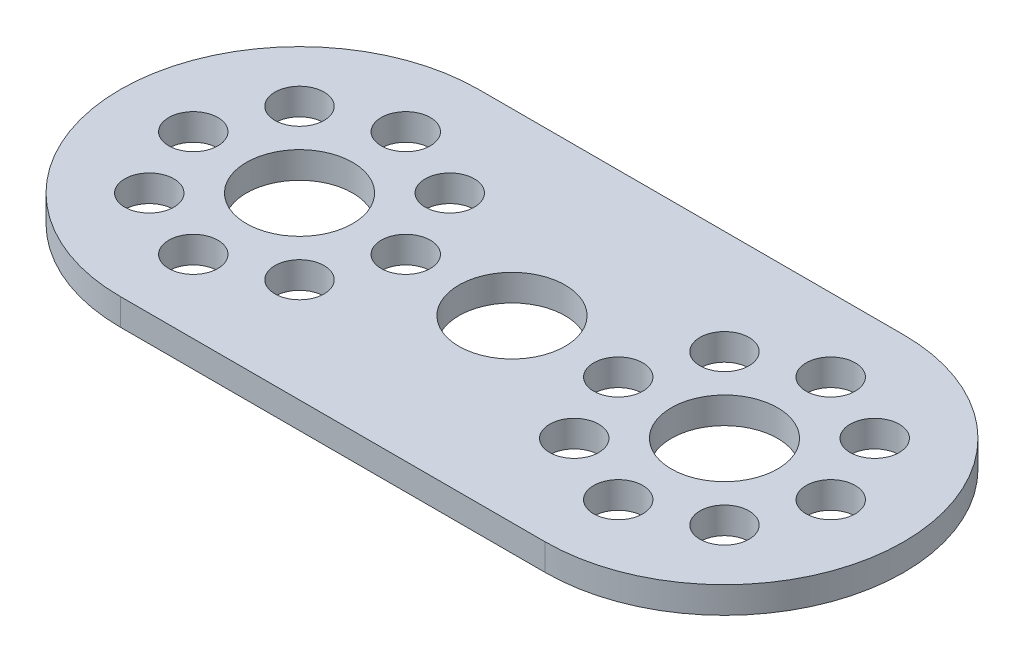
from build123d import *

# Parameters (mm, degrees)
SKETCH1_R           = 4
SKETCH1_R_2         = 1.85
BOSS_EXTRUDE1_DEPTH = 2


with BuildPart() as part:
    # Sketch1 → Boss-Extrude1 (new body)
    with BuildSketch(Plane(origin=(0, 0, 0), x_dir=(1, 0, 0), z_dir=(0, 1, 0))):
        with BuildLine():
            Line((-16, 13.5), (16, 13.5))
            ThreePointArc((16, 13.5), (29.5, 0), (16, -13.5))
            Line((16, -13.5), (-16, -13.5))
            ThreePointArc((-16, -13.5), (-29.5, 0), (-16, 13.5))
        make_face()
        Circle(SKETCH1_R, mode=Mode.SUBTRACT)
        with Locations((16, 0)):
            Circle(SKETCH1_R, mode=Mode.SUBTRACT)
        with Locations((8, 0)):
            Circle(SKETCH1_R_2, mode=Mode.SUBTRACT)
        with Locations((10.343145751, 5.656854249)):
            Circle(SKETCH1_R_2, mode=Mode.SUBTRACT)
        with Locations((16, 8)):
            Circle(SKETCH1_R_2, mode=Mode.SUBTRACT)
        with Locations((21.656854249, 5.656854249)):
            Circle(SKETCH1_R_2, mode=Mode.SUBTRACT)
        with Locations((24, 0)):
            Circle(SKETCH1_R_2, mode=Mode.SUBTRACT)
        with Locations((21.656854249, -5.656854249)):
            Circle(SKETCH1_R_2, mode=Mode.SUBTRACT)
        with Locations((16, -8)):
            Circle(SKETCH1_R_2, mode=Mode.SUBTRACT)
        with Locations((10.343145751, -5.656854249)):
            Circle(SKETCH1_R_2, mode=Mode.SUBTRACT)
        with Locations((-10.343145751, -5.656854249)):
            Circle(SKETCH1_R_2, mode=Mode.SUBTRACT)
        with Locations((-16, -8)):
            Circle(SKETCH1_R_2, mode=Mode.SUBTRACT)
        with Locations((-21.656854249, -5.656854249)):
            Circle(SKETCH1_R_2, mode=Mode.SUBTRACT)
        with Locations((-24, 0)):
            Circle(SKETCH1_R_2, mode=Mode.SUBTRACT)
        with Locations((-21.656854249, 5.656854249)):
            Circle(SKETCH1_R_2, mode=Mode.SUBTRACT)
        with Locations((-16, 8)):
            Circle(SKETCH1_R_2, mode=Mode.SUBTRACT)
        with Locations((-10.343145751, 5.656854249)):
            Circle(SKETCH1_R_2, mode=Mode.SUBTRACT)
        with Locations((-8, 0)):
            Circle(SKETCH1_R_2, mode=Mode.SUBTRACT)
        with Locations((-16, 0)):
            Circle(SKETCH1_R, mode=Mode.SUBTRACT)
    extrude(amount=BOSS_EXTRUDE1_DEPTH)


solid = part.part
